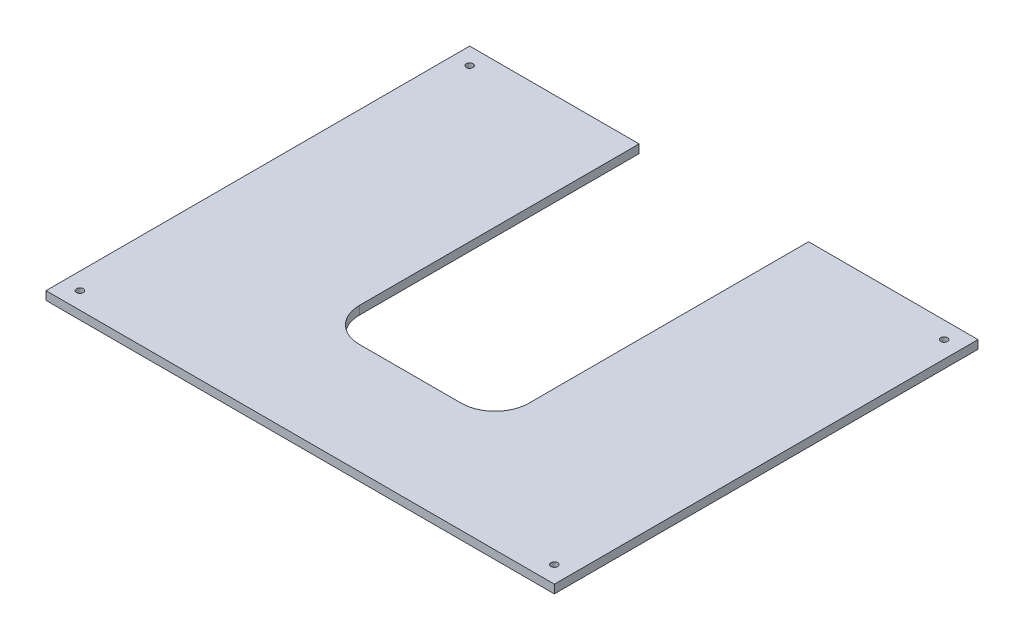
from build123d import *

# Parameters (mm, degrees)
SKETCH1_W           = 300
SKETCH1_H           = 250
SKETCH1_R           = 2
BOSS_EXTRUDE1_DEPTH = 5
SKETCH2_W           = 100
SKETCH2_H           = 185
CUT_EXTRUDE1_DEPTH  = 6
FILLET1_R           = 20


with BuildPart() as part:
    # Sketch1 → Boss-Extrude1 (new body)
    with BuildSketch(Plane(origin=(0, 0, 0), x_dir=(1, 0, 0), z_dir=(0, 1, 0))):
        Rectangle(SKETCH1_W, SKETCH1_H)
        with Locations((-140, -115)):
            Circle(SKETCH1_R, mode=Mode.SUBTRACT)
        with Locations((-140, 115)):
            Circle(SKETCH1_R, mode=Mode.SUBTRACT)
        with Locations((140, -115)):
            Circle(SKETCH1_R, mode=Mode.SUBTRACT)
        with Locations((140, 115)):
            Circle(SKETCH1_R, mode=Mode.SUBTRACT)
    extrude(amount=BOSS_EXTRUDE1_DEPTH)

    # Sketch2 → Cut-Extrude1 (cut, through all)
    with BuildSketch(Plane(origin=(0, 5, 0), x_dir=(1, 0, 0), z_dir=(0, 1, 0))):
        with Locations((0, 32.5)):
            Rectangle(SKETCH2_W, SKETCH2_H)
    extrude(amount=-CUT_EXTRUDE1_DEPTH, mode=Mode.SUBTRACT)

    # Fillet1
    fillet1_edges = [part.edges().sort_by_distance(p)[0] for p in [
        (-50, 2.5, 60),
        (50, 2.5, 60),
    ]]
    fillet(fillet1_edges, radius=FILLET1_R)


solid = part.part
